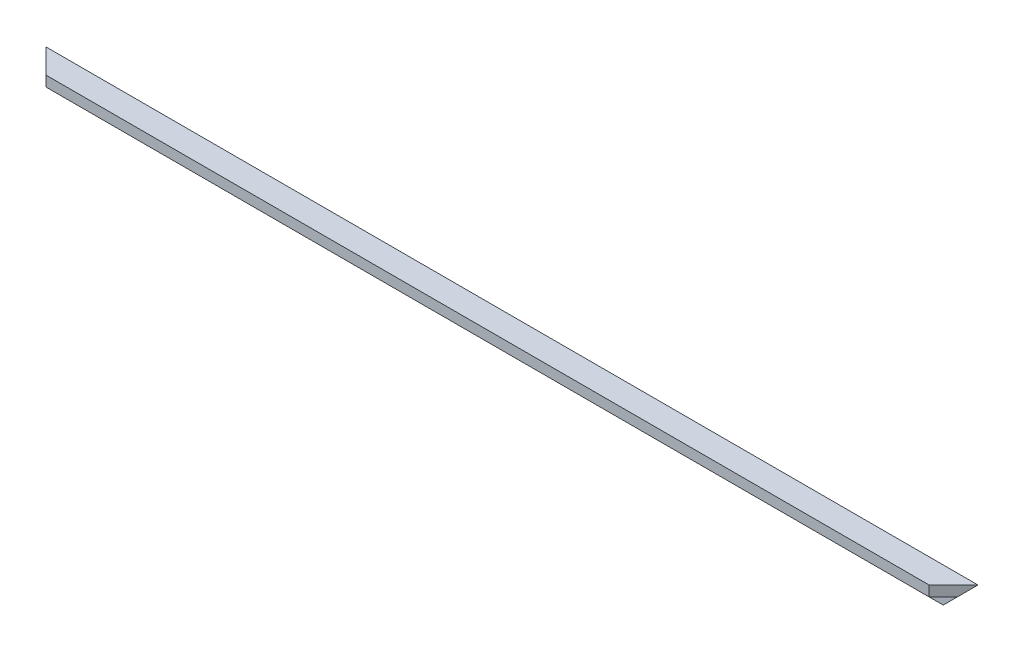
from build123d import *

# Parameters (mm, degrees)
BOSS_EXTRU_1_DEPTH      = 1527
ENL_V_MAT_EXTRU_1_DEPTH = 41
ENL_V_MAT_EXTRU_2_DEPTH = 41


with BuildPart() as part:
    # Esquisse1 → Boss.-Extru.1 (new body)
    with BuildSketch(Plane(origin=(0, 0, 0), x_dir=(0, 0, -1), z_dir=(1, 0, 0))):
        Polygon((0, 0), (-40, 0), (-40, -17), (-17, -17), (-17, -40), (0, -40), align=None)
    extrude(amount=BOSS_EXTRU_1_DEPTH)

    # Esquisse2 → Enlèv. mat.-Extru.1 (cut, through all)
    with BuildSketch(Plane(origin=(0, 0, 0), x_dir=(1, 0, 0), z_dir=(0, 1, 0))):
        Polygon((1527, 0), (1487, -40), (1527, -40), align=None)
        Polygon((0, 0), (0, -40), (40, -40), align=None)
    extrude(amount=-ENL_V_MAT_EXTRU_1_DEPTH, mode=Mode.SUBTRACT)

    # Esquisse3 → Enlèv. mat.-Extru.2 (cut, through all)
    with BuildSketch(Plane(origin=(0, 0, 0), x_dir=(-1, 0, 0), z_dir=(0, 0, -1))):
        Polygon((-1527, 0), (-1487, -40), (-1527, -40), align=None)
        Polygon((-40, -40), (0, -40), (0, 0), align=None)
    extrude(amount=-ENL_V_MAT_EXTRU_2_DEPTH, mode=Mode.SUBTRACT)


solid = part.part
